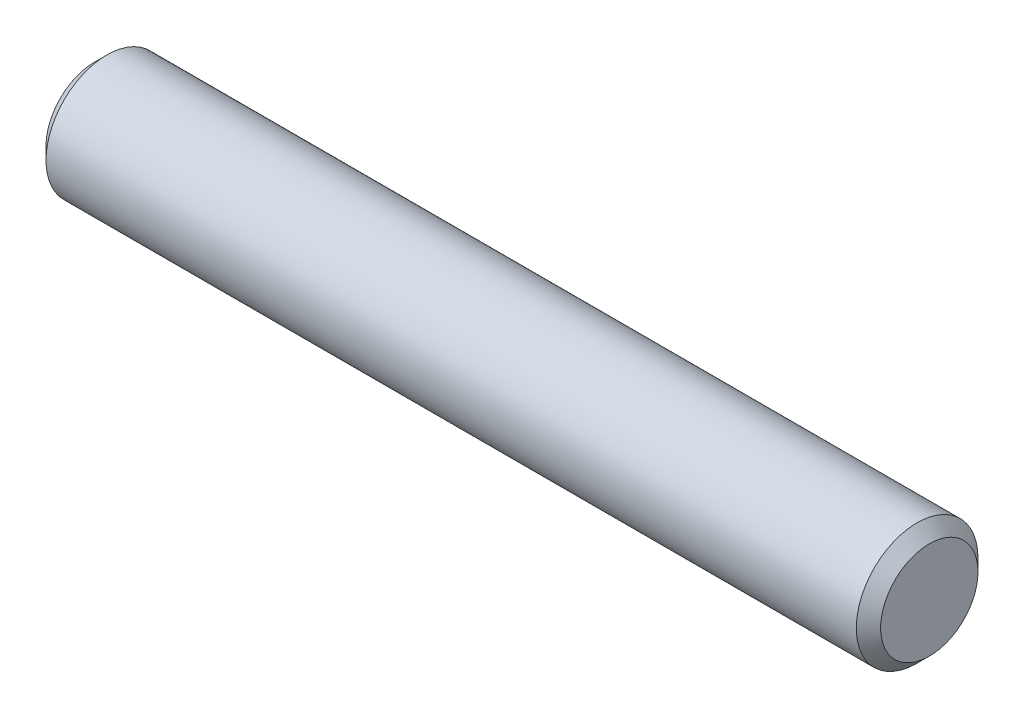
from build123d import *

# Parameters (mm, degrees)
SKETCH2_R           = 2.778125
EXTRUDE1_DEPTH      = 19.05
EXTRUDE1_DEPTH_BACK = 19.05
CHAMFER1_SIZE       = 0.555625


with BuildPart() as part:
    # Sketch2 → Extrude1 (new body, two sides)
    with BuildSketch(Plane(origin=(0, 0, 0), x_dir=(0, 0, -1), z_dir=(1, 0, 0))) as extrude1_sk:
        Circle(SKETCH2_R)
    extrude(amount=EXTRUDE1_DEPTH)
    extrude(extrude1_sk.sketch, amount=-EXTRUDE1_DEPTH_BACK)

    # Chamfer1
    chamfer1_edges = [part.edges().sort_by_distance(p)[0] for p in [
        (-19.05, 0, 2.778125),
        (19.05, 0, 2.778125),
    ]]
    chamfer(chamfer1_edges, length=CHAMFER1_SIZE)


solid = part.part
